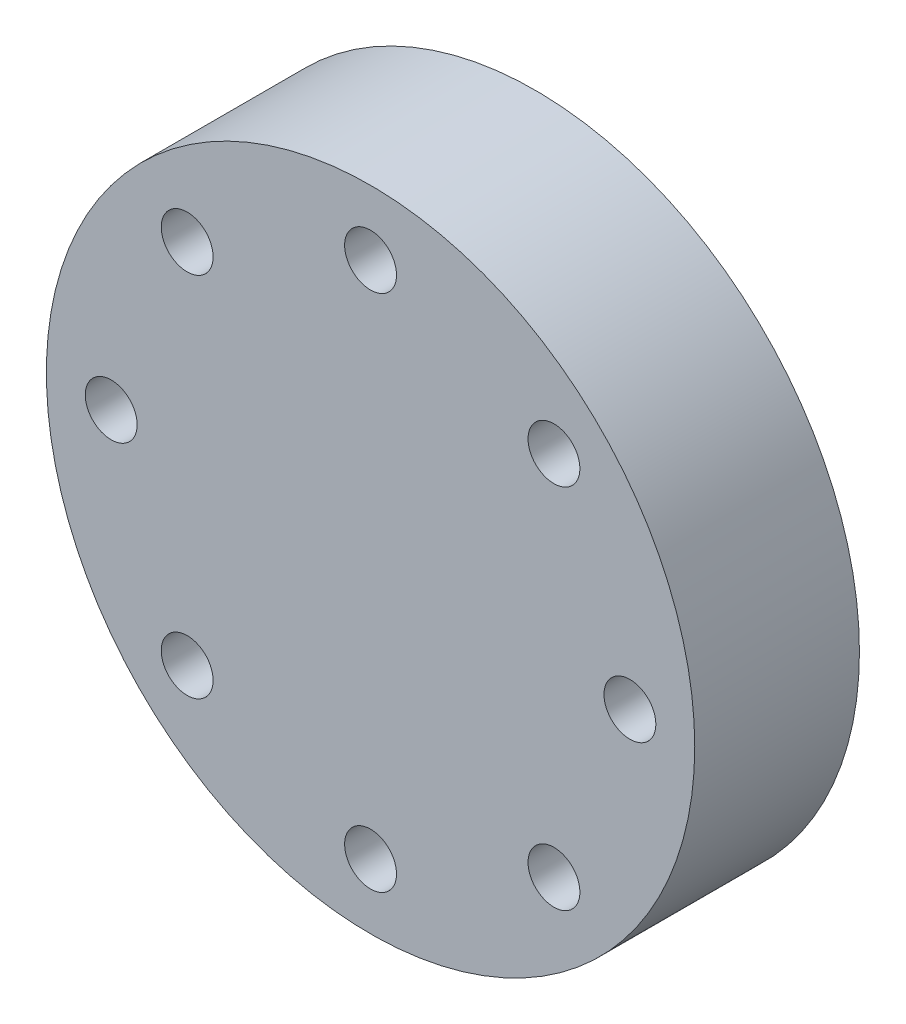
from build123d import *

# Parameters (mm, degrees)
ESBO_O1_R                = 50
ESBO_O1_R_2              = 4
RESSALTO_EXTRUS_O1_DEPTH = 25.4


with BuildPart() as part:
    # Esboço1 → Ressalto-extrusão1 (new body)
    with BuildSketch(Plane.XY):
        Circle(ESBO_O1_R)
        with Locations((0, 40)):
            Circle(ESBO_O1_R_2, mode=Mode.SUBTRACT)
        with Locations((28.284271247, 28.284271247)):
            Circle(ESBO_O1_R_2, mode=Mode.SUBTRACT)
        with Locations((40, 0)):
            Circle(ESBO_O1_R_2, mode=Mode.SUBTRACT)
        with Locations((28.284271247, -28.284271247)):
            Circle(ESBO_O1_R_2, mode=Mode.SUBTRACT)
        with Locations((0, -40)):
            Circle(ESBO_O1_R_2, mode=Mode.SUBTRACT)
        with Locations((-28.284271247, -28.284271247)):
            Circle(ESBO_O1_R_2, mode=Mode.SUBTRACT)
        with Locations((-40, 0)):
            Circle(ESBO_O1_R_2, mode=Mode.SUBTRACT)
        with Locations((-28.284271247, 28.284271247)):
            Circle(ESBO_O1_R_2, mode=Mode.SUBTRACT)
    extrude(amount=RESSALTO_EXTRUS_O1_DEPTH)


solid = part.part
